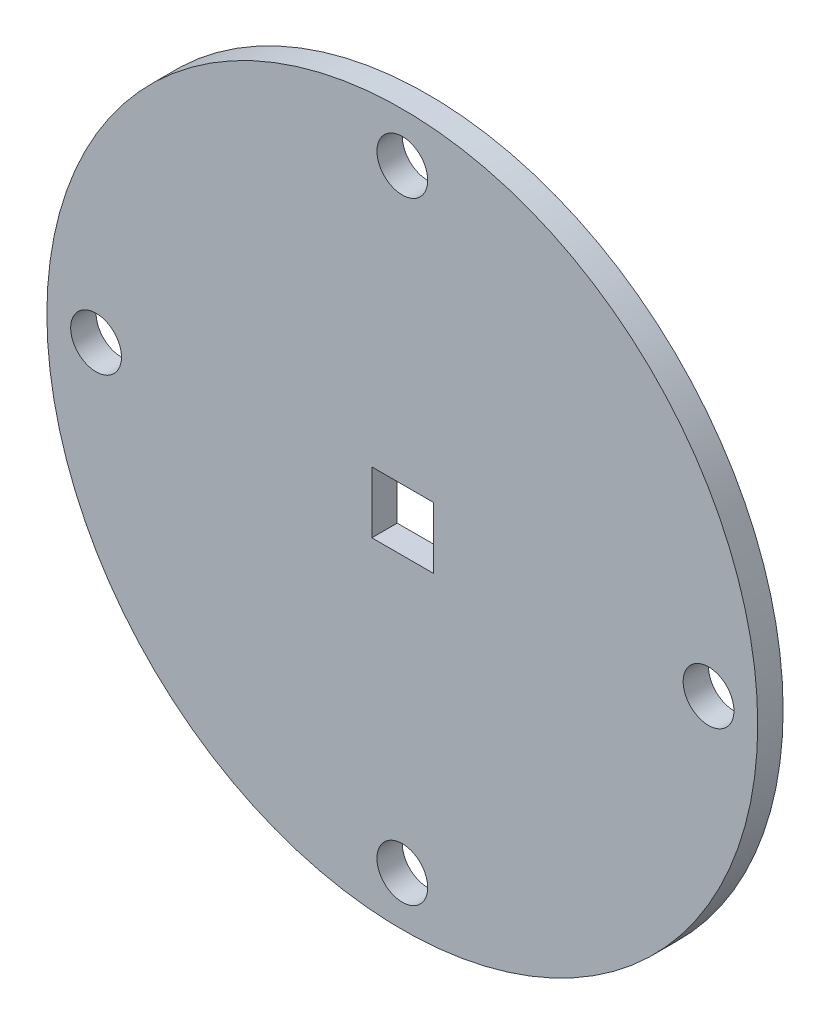
from build123d import *

# Parameters (mm, degrees)
SKETCH1_R           = 70
SKETCH1_R_2         = 5
SKETCH1_W           = 12.1
SKETCH1_H           = 12.1
BOSS_EXTRUDE1_DEPTH = 5


with BuildPart() as part:
    # Sketch1 → Boss-Extrude1 (new body)
    with BuildSketch(Plane.XY):
        Circle(SKETCH1_R)
        with Locations((0, 60.31)):
            Circle(SKETCH1_R_2, mode=Mode.SUBTRACT)
        with Locations((60.31, 0)):
            Circle(SKETCH1_R_2, mode=Mode.SUBTRACT)
        with Locations((0, -60.31)):
            Circle(SKETCH1_R_2, mode=Mode.SUBTRACT)
        with Locations((-60.31, 0)):
            Circle(SKETCH1_R_2, mode=Mode.SUBTRACT)
        with Locations((0.05, -0.1)):
            Rectangle(SKETCH1_W, SKETCH1_H, mode=Mode.SUBTRACT)
    extrude(amount=BOSS_EXTRUDE1_DEPTH)


solid = part.part
